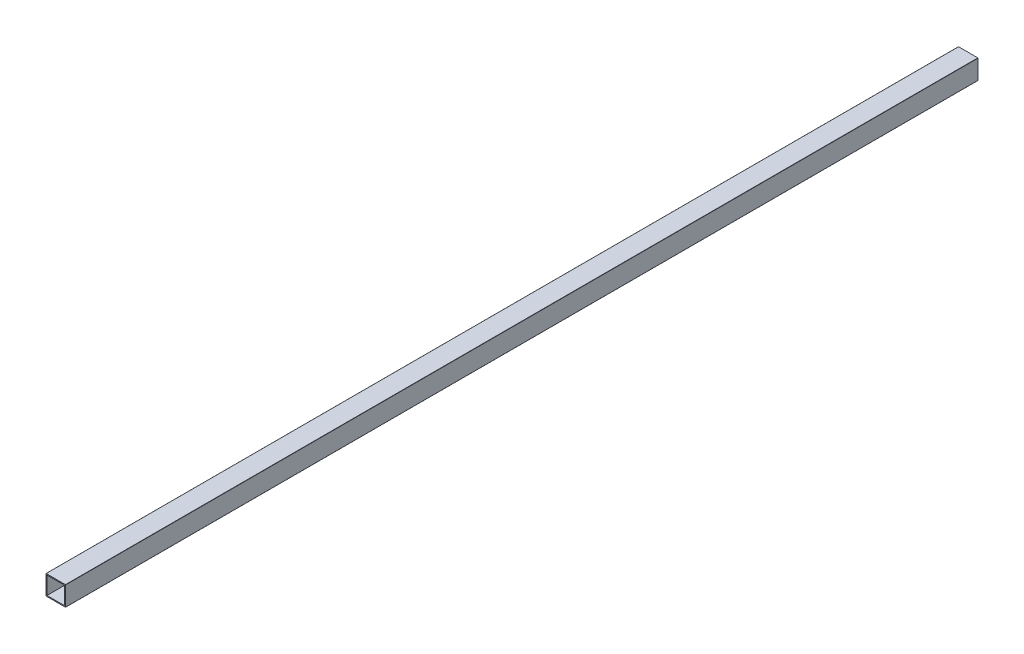
from build123d import *

# Parameters (mm, degrees)
SKETCH1_W           = 18
SKETCH1_H           = 18
BOSS_EXTRUDE1_DEPTH = 930


with BuildPart() as part:
    # Sketch1 → Boss-Extrude1 (new body)
    with BuildSketch(Plane.XY):
        with BuildLine():
            Line((0.2, 0), (19.8, 0))
            ThreePointArc((19.8, 0), (19.941421356, 0.058578644), (20, 0.2))
            Line((20, 0.2), (20, 19.8))
            ThreePointArc((20, 19.8), (19.941421356, 19.941421356), (19.8, 20))
            Line((19.8, 20), (0.2, 20))
            ThreePointArc((0.2, 20), (0.058578644, 19.941421356), (0, 19.8))
            Line((0, 19.8), (0, 0.2))
            ThreePointArc((0, 0.2), (0.058578644, 0.058578644), (0.2, 0))
        make_face()
        with Locations((10, 10)):
            Rectangle(SKETCH1_W, SKETCH1_H, mode=Mode.SUBTRACT)
    extrude(amount=BOSS_EXTRUDE1_DEPTH)


solid = part.part
